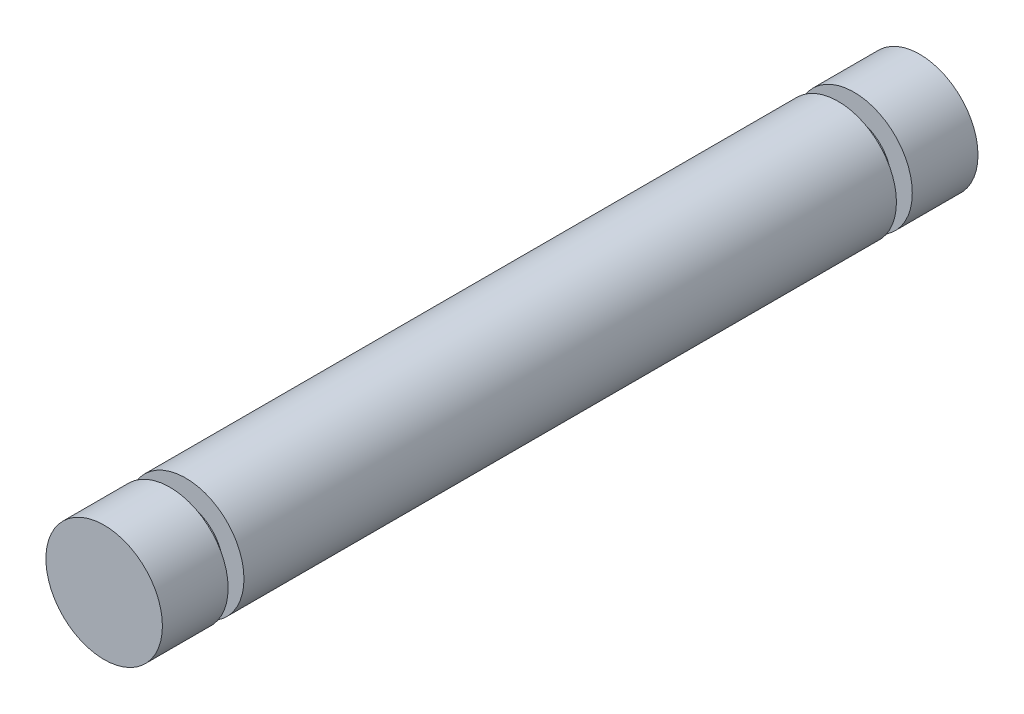
from build123d import *

# Parameters (mm, degrees)
SKETCH1_R           = 2.5
BOSS_EXTRUDE1_DEPTH = 35
SKETCH2_W           = 0.68
SKETCH2_H           = 0.9


with BuildPart() as part:
    # Sketch1 → Boss-Extrude1 (new body)
    with BuildSketch(Plane.XY):
        Circle(SKETCH1_R)
    extrude(amount=BOSS_EXTRUDE1_DEPTH)

    # Sketch2 → Cut-Revolve1 (revolve, cut)
    with BuildSketch(Plane(origin=(0, 0, 0), x_dir=(0, 0, -1), z_dir=(1, 0, 0))):
        with Locations((-31.84, 2.05)):
            Rectangle(SKETCH2_W, SKETCH2_H)
        with Locations((-3.16, 2.05)):
            Rectangle(SKETCH2_W, SKETCH2_H)
    revolve(axis=Axis((0, 0, 35), (0, 0, -1)), mode=Mode.SUBTRACT)


solid = part.part
